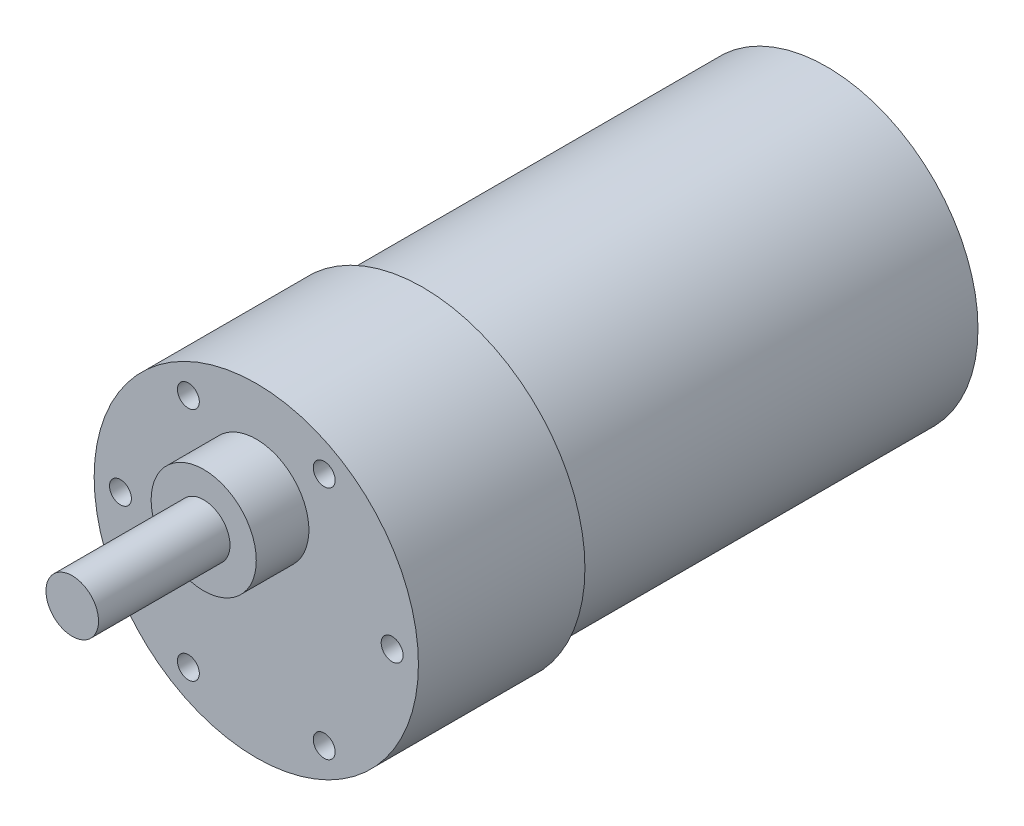
from build123d import *

# Parameters (mm, degrees)
SKETCH4_R                       = 6
BOSS_EXTRUDE3_DEPTH             = 6
SKETCH4_3_R                     = 3
BOSS_EXTRUDE4_DEPTH             = 21
TAP_DRILL_FOR_M3X0_5_TAP1_D     = 2.5
TAP_DRILL_FOR_M3X0_5_TAP1_DEPTH = 10
TAP_DRILL_FOR_M3X0_5_TAP1_TIP   = 0.751075774


with BuildPart() as part:
    # Sketch3 → Revolve1 (revolve)
    with BuildSketch(Plane(origin=(0, 0, 0), x_dir=(0, 0, -1), z_dir=(1, 0, 0))):
        Polygon((0, 0), (0, 18.5), (19, 18.5), (19, 17.25), (49.8, 17.25), (65.1, 17.25), (65.1, 0), align=None)
    revolve(axis=Axis((0, 0, 4.918404278), (0, 0, -1)))

    # Sketch4 → Boss-Extrude3 (add)
    with BuildSketch(Plane.XY):
        with Locations((0, 7)):
            Circle(SKETCH4_R)
    extrude(amount=BOSS_EXTRUDE3_DEPTH)

    # Sketch4_3 → Boss-Extrude4 (add)
    with BuildSketch(Plane.XY):
        with Locations((0, 7)):
            Circle(SKETCH4_3_R)
    extrude(amount=BOSS_EXTRUDE4_DEPTH)

    # Tap Drill for M3x0.5 Tap1
    with Locations(Plane.XY):
        with Locations((-15.5, 0), (-7.75, 13.423393759), (7.75, 13.423393759), (15.5, 0), (7.75, -13.423393759), (-7.75, -13.423393759)):
            Hole(TAP_DRILL_FOR_M3X0_5_TAP1_D / 2, depth=TAP_DRILL_FOR_M3X0_5_TAP1_DEPTH)
            with Locations((0, 0, -(TAP_DRILL_FOR_M3X0_5_TAP1_DEPTH + TAP_DRILL_FOR_M3X0_5_TAP1_TIP / 2))):  # 118° drill point
                Cone(0, TAP_DRILL_FOR_M3X0_5_TAP1_D / 2, TAP_DRILL_FOR_M3X0_5_TAP1_TIP, mode=Mode.SUBTRACT)


solid = part.part
